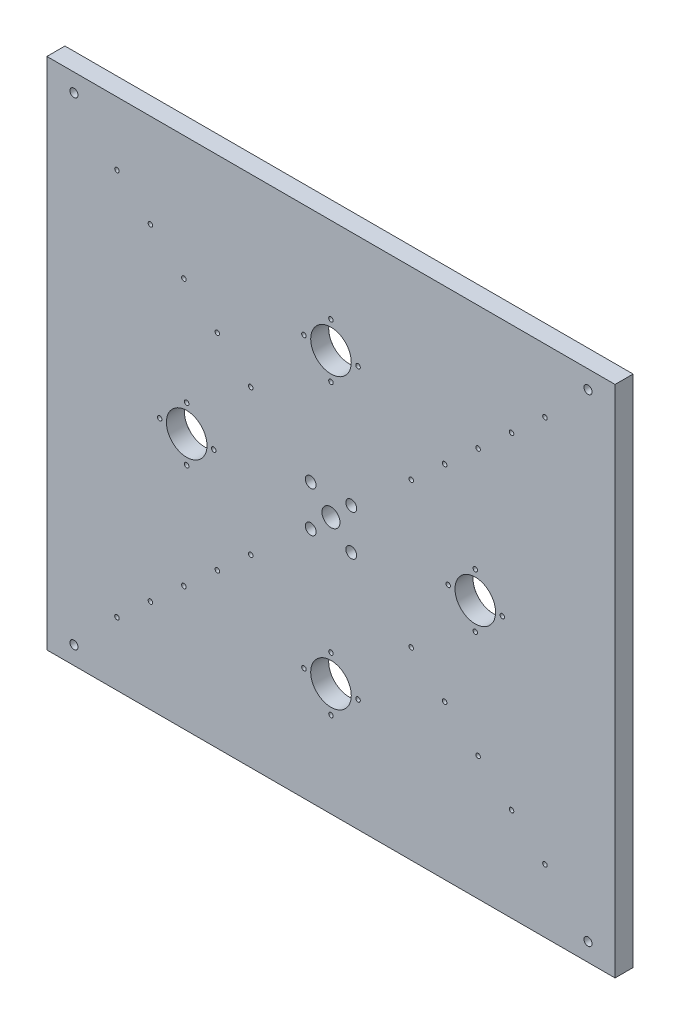
from build123d import *

# Parameters (mm, degrees)
SKETCH_1_W                  = 630
SKETCH_1_H                  = 570
EXTRUDE_1_DEPTH             = 20
MM_2_D                      = 20
MM_2_DEPTH                  = 20
MM_2_CSINK_D                = 20.05
MM_2_CSINK_ANGLE            = 90
MM_2_TIP                    = 6.00860619
HOLE_WIZARD_1_AT_2_COUNT    = 2
HOLE_WIZARD_1_AT_2_PITCH    = 570
HOLE_WIZARD_1_AT_3_COUNT    = 2
HOLE_WIZARD_1_AT_3_PITCH    = 778.331548892
HOLE_WIZARD_1_AT_4_COUNT    = 2
HOLE_WIZARD_1_AT_4_PITCH    = 530
HOLE_WIZARD_M6_1_AT_2_COUNT = 2
HOLE_WIZARD_M6_1_AT_2_PITCH = 50
HOLE_WIZARD_M6_1_AT_3_COUNT = 2
HOLE_WIZARD_M6_1_AT_3_PITCH = 100
HOLE_WIZARD_M6_1_AT_4_COUNT = 2
HOLE_WIZARD_M6_1_AT_4_PITCH = 150
HOLE_WIZARD_M6_1_AT_5_COUNT = 2
HOLE_WIZARD_M6_1_AT_5_PITCH = 200
MM_4_D                      = 12
MM_4_DEPTH                  = 22
MM_4_CSINK_D                = 12.05
MM_4_CSINK_ANGLE            = 90
MM_4_TIP                    = 3.605163714
MM_1_D                      = 45
MM_1_DEPTH                  = 24.5
MM_1_CSINK_D                = 45.1
MM_1_CSINK_ANGLE            = 90
MM_1_TIP                    = 13.519363928
HOLE_WIZARD_M6_2_AT_2_COUNT = 2
HOLE_WIZARD_M6_2_AT_2_PITCH = 42.426406871
HOLE_WIZARD_M6_2_AT_3_COUNT = 2
HOLE_WIZARD_M6_2_AT_3_PITCH = 60
HOLE_WIZARD_M6_2_AT_4_COUNT = 2
HOLE_WIZARD_M6_2_AT_4_PITCH = 42.426406871
HOLE_WIZARD_M6_3_AT_2_COUNT = 2
HOLE_WIZARD_M6_3_AT_2_PITCH = 42.426406871
HOLE_WIZARD_M6_3_AT_3_COUNT = 2
HOLE_WIZARD_M6_3_AT_3_PITCH = 60
HOLE_WIZARD_M6_3_AT_4_COUNT = 2
HOLE_WIZARD_M6_3_AT_4_PITCH = 42.426406871


with BuildPart() as part:
    # 草图1 → 凸台-拉伸1 (new body)
    with BuildSketch(Plane.XY):
        Rectangle(SKETCH_1_W, SKETCH_1_H)
    extrude(amount=EXTRUDE_1_DEPTH)

    # 大小mm 暗销槽口2
    with Locations(Plane(origin=(0, 0, 0), x_dir=(-1, 0, 0), z_dir=(0, 0, -1))):
        with Locations((0, 0)):
            CounterSinkHole(MM_2_D / 2, MM_2_CSINK_D / 2, depth=MM_2_DEPTH, counter_sink_angle=MM_2_CSINK_ANGLE)
            with Locations((0, 0, -(MM_2_DEPTH + MM_2_TIP / 2))):  # 118° drill point
                Cone(0, MM_2_D / 2, MM_2_TIP, mode=Mode.SUBTRACT)

    # 草图5 → 打孔尺寸(%根据)内六角圆柱头螺钉的类型1 (revolve, cut)
    with BuildSketch(Plane(origin=(285, 265, 0), x_dir=(0, 1, 0), z_dir=(1, 0, 0))):
        Polygon((0, 0), (0, 22.703872786), (4.5, 20), (4.5, 9), (7.5, 9), (7.5, 0.025), (7.525, 0), align=None)
    hole_wizard_1 = revolve(axis=Axis((285, 265, -6.35), (0, 0, 1)), mode=Mode.SUBTRACT)

    # 打孔尺寸(%根据)内六角圆柱头螺钉的类型1 at 2: 打孔尺寸(%根据)内六角圆柱头螺钉的类型1 ×2
    with Locations(*[(-i * HOLE_WIZARD_1_AT_2_PITCH, 0, 0) for i in range(1, HOLE_WIZARD_1_AT_2_COUNT)]):
        add(hole_wizard_1, mode=Mode.SUBTRACT)

    # 打孔尺寸(%根据)内六角圆柱头螺钉的类型1 at 3: 打孔尺寸(%根据)内六角圆柱头螺钉的类型1 ×2
    with Locations(*[Vector(-0.732335726, -0.680943745, 0) * (i * HOLE_WIZARD_1_AT_3_PITCH) for i in range(1, HOLE_WIZARD_1_AT_3_COUNT)]):
        add(hole_wizard_1, mode=Mode.SUBTRACT)

    # 打孔尺寸(%根据)内六角圆柱头螺钉的类型1 at 4: 打孔尺寸(%根据)内六角圆柱头螺钉的类型1 ×2
    with Locations(*[(0, -i * HOLE_WIZARD_1_AT_4_PITCH, 0) for i in range(1, HOLE_WIZARD_1_AT_4_COUNT)]):
        add(hole_wizard_1, mode=Mode.SUBTRACT)

    # 草图6 → M6 螺纹孔1 (revolve, cut)
    with BuildSketch(Plane(origin=(237.29144932, -214.69226367, 0), x_dir=(0, 1, 0), z_dir=(1, 0, 0))):
        Polygon((0, 0), (0, 31.502151548), (2.5, 30), (2.5, 0.525), (3.025, 0), align=None)
    hole_wizard_m6_1 = revolve(axis=Axis((237.29144932, -214.69226367, -6.35), (0, 0, 1)), mode=Mode.SUBTRACT)

    # M6 螺纹孔1 at 2: M6 螺纹孔1 ×2
    with Locations(*[Vector(-0.741535779, 0.670913324, 0) * (i * HOLE_WIZARD_M6_1_AT_2_PITCH) for i in range(1, HOLE_WIZARD_M6_1_AT_2_COUNT)]):
        add(hole_wizard_m6_1, mode=Mode.SUBTRACT)

    # M6 螺纹孔1 at 3: M6 螺纹孔1 ×2
    with Locations(*[Vector(-0.741535779, 0.670913324, 0) * (i * HOLE_WIZARD_M6_1_AT_3_PITCH) for i in range(1, HOLE_WIZARD_M6_1_AT_3_COUNT)]):
        add(hole_wizard_m6_1, mode=Mode.SUBTRACT)

    # M6 螺纹孔1 at 4: M6 螺纹孔1 ×2
    with Locations(*[Vector(-0.741535779, 0.670913324, 0) * (i * HOLE_WIZARD_M6_1_AT_4_PITCH) for i in range(1, HOLE_WIZARD_M6_1_AT_4_COUNT)]):
        add(hole_wizard_m6_1, mode=Mode.SUBTRACT)

    # M6 螺纹孔1 at 5: M6 螺纹孔1 ×2
    with Locations(*[Vector(-0.741535779, 0.670913324, 0) * (i * HOLE_WIZARD_M6_1_AT_5_PITCH) for i in range(1, HOLE_WIZARD_M6_1_AT_5_COUNT)]):
        add(hole_wizard_m6_1, mode=Mode.SUBTRACT)

    # 镜向1: M6 螺纹孔1 across plane
    add(hole_wizard_m6_1.mirror(Plane(origin=(0, 0, 0), x_dir=(0, 0, 1), z_dir=(1, 0, 0))), mode=Mode.SUBTRACT)

    # 镜向1 copy 1 sketch → 镜向1 copy 1 (revolve, cut)
    with BuildSketch(Plane(origin=(-200.214660363, -181.146597472, 0), x_dir=(0, 1, 0), z_dir=(-1, 0, 0))):
        Polygon((0, 0), (0, -31.502151548), (2.5, -30), (2.5, -0.525), (3.025, 0), align=None)
    revolve(axis=Axis((-200.214660363, -181.146597472, -6.35), (0, 0, -1)), mode=Mode.SUBTRACT)

    # 镜向1 copy 2 sketch → 镜向1 copy 2 (revolve, cut)
    with BuildSketch(Plane(origin=(-163.137871407, -147.600931273, 0), x_dir=(0, 1, 0), z_dir=(-1, 0, 0))):
        Polygon((0, 0), (0, -31.502151548), (2.5, -30), (2.5, -0.525), (3.025, 0), align=None)
    revolve(axis=Axis((-163.137871407, -147.600931273, -6.35), (0, 0, -1)), mode=Mode.SUBTRACT)

    # 镜向1 copy 3 sketch → 镜向1 copy 3 (revolve, cut)
    with BuildSketch(Plane(origin=(-126.061082451, -114.055265075, 0), x_dir=(0, 1, 0), z_dir=(-1, 0, 0))):
        Polygon((0, 0), (0, -31.502151548), (2.5, -30), (2.5, -0.525), (3.025, 0), align=None)
    revolve(axis=Axis((-126.061082451, -114.055265075, -6.35), (0, 0, -1)), mode=Mode.SUBTRACT)

    # 镜向1 copy 4 sketch → 镜向1 copy 4 (revolve, cut)
    with BuildSketch(Plane(origin=(-88.984293495, -80.509598876, 0), x_dir=(0, 1, 0), z_dir=(-1, 0, 0))):
        Polygon((0, 0), (0, -31.502151548), (2.5, -30), (2.5, -0.525), (3.025, 0), align=None)
    revolve(axis=Axis((-88.984293495, -80.509598876, -6.35), (0, 0, -1)), mode=Mode.SUBTRACT)

    # 镜向2: M6 螺纹孔1 across plane
    add(hole_wizard_m6_1.mirror(Plane.ZX), mode=Mode.SUBTRACT)

    # 镜向2 copy 1 sketch → 镜向2 copy 1 (revolve, cut)
    with BuildSketch(Plane(origin=(200.214660363, 181.146597472, 0), x_dir=(0, -1, 0), z_dir=(1, 0, 0))):
        Polygon((0, 0), (0, -31.502151548), (2.5, -30), (2.5, -0.525), (3.025, 0), align=None)
    revolve(axis=Axis((200.214660363, 181.146597472, -6.35), (0, 0, -1)), mode=Mode.SUBTRACT)

    # 镜向2 copy 2 sketch → 镜向2 copy 2 (revolve, cut)
    with BuildSketch(Plane(origin=(163.137871407, 147.600931273, 0), x_dir=(0, -1, 0), z_dir=(1, 0, 0))):
        Polygon((0, 0), (0, -31.502151548), (2.5, -30), (2.5, -0.525), (3.025, 0), align=None)
    revolve(axis=Axis((163.137871407, 147.600931273, -6.35), (0, 0, -1)), mode=Mode.SUBTRACT)

    # 镜向2 copy 3 sketch → 镜向2 copy 3 (revolve, cut)
    with BuildSketch(Plane(origin=(126.061082451, 114.055265075, 0), x_dir=(0, -1, 0), z_dir=(1, 0, 0))):
        Polygon((0, 0), (0, -31.502151548), (2.5, -30), (2.5, -0.525), (3.025, 0), align=None)
    revolve(axis=Axis((126.061082451, 114.055265075, -6.35), (0, 0, -1)), mode=Mode.SUBTRACT)

    # 镜向2 copy 4 sketch → 镜向2 copy 4 (revolve, cut)
    with BuildSketch(Plane(origin=(88.984293495, 80.509598876, 0), x_dir=(0, -1, 0), z_dir=(1, 0, 0))):
        Polygon((0, 0), (0, -31.502151548), (2.5, -30), (2.5, -0.525), (3.025, 0), align=None)
    revolve(axis=Axis((88.984293495, 80.509598876, -6.35), (0, 0, -1)), mode=Mode.SUBTRACT)

    # 镜向2 copy 5 sketch → 镜向2 copy 5 (revolve, cut)
    with BuildSketch(Plane(origin=(-237.29144932, 214.69226367, 0), x_dir=(0, -1, 0), z_dir=(-1, 0, 0))):
        Polygon((0, 0), (0, 31.502151548), (2.5, 30), (2.5, 0.525), (3.025, 0), align=None)
    revolve(axis=Axis((-237.29144932, 214.69226367, -6.35), (0, 0, 1)), mode=Mode.SUBTRACT)

    # 镜向2 copy 6 sketch → 镜向2 copy 6 (revolve, cut)
    with BuildSketch(Plane(origin=(-200.214660363, 181.146597472, 0), x_dir=(0, -1, 0), z_dir=(-1, 0, 0))):
        Polygon((0, 0), (0, 31.502151548), (2.5, 30), (2.5, 0.525), (3.025, 0), align=None)
    revolve(axis=Axis((-200.214660363, 181.146597472, -6.35), (0, 0, 1)), mode=Mode.SUBTRACT)

    # 镜向2 copy 7 sketch → 镜向2 copy 7 (revolve, cut)
    with BuildSketch(Plane(origin=(-163.137871407, 147.600931273, 0), x_dir=(0, -1, 0), z_dir=(-1, 0, 0))):
        Polygon((0, 0), (0, 31.502151548), (2.5, 30), (2.5, 0.525), (3.025, 0), align=None)
    revolve(axis=Axis((-163.137871407, 147.600931273, -6.35), (0, 0, 1)), mode=Mode.SUBTRACT)

    # 镜向2 copy 8 sketch → 镜向2 copy 8 (revolve, cut)
    with BuildSketch(Plane(origin=(-126.061082451, 114.055265075, 0), x_dir=(0, -1, 0), z_dir=(-1, 0, 0))):
        Polygon((0, 0), (0, 31.502151548), (2.5, 30), (2.5, 0.525), (3.025, 0), align=None)
    revolve(axis=Axis((-126.061082451, 114.055265075, -6.35), (0, 0, 1)), mode=Mode.SUBTRACT)

    # 镜向2 copy 9 sketch → 镜向2 copy 9 (revolve, cut)
    with BuildSketch(Plane(origin=(-88.984293495, 80.509598876, 0), x_dir=(0, -1, 0), z_dir=(-1, 0, 0))):
        Polygon((0, 0), (0, 31.502151548), (2.5, 30), (2.5, 0.525), (3.025, 0), align=None)
    revolve(axis=Axis((-88.984293495, 80.509598876, -6.35), (0, 0, 1)), mode=Mode.SUBTRACT)

    # 大小mm 暗销槽口4
    with Locations(Plane(origin=(0, 0, 0), x_dir=(-1, 0, 0), z_dir=(0, 0, -1))):
        with Locations((22.5, 22.5), (22.5, -22.5), (-22.5, -22.5), (-22.5, 22.5)):
            CounterSinkHole(MM_4_D / 2, MM_4_CSINK_D / 2, depth=MM_4_DEPTH, counter_sink_angle=MM_4_CSINK_ANGLE)
            with Locations((0, 0, -(MM_4_DEPTH + MM_4_TIP / 2))):  # 118° drill point
                Cone(0, MM_4_D / 2, MM_4_TIP, mode=Mode.SUBTRACT)

    # 大小mm 暗销孔1
    with Locations(Plane(origin=(160, 0, 0), x_dir=(-1, 0, 0), z_dir=(0, 0, -1))):
        with Locations((0, 0), (160, 160), (320, 0), (160, -160)):
            CounterSinkHole(MM_1_D / 2, MM_1_CSINK_D / 2, depth=MM_1_DEPTH, counter_sink_angle=MM_1_CSINK_ANGLE)
            with Locations((0, 0, -(MM_1_DEPTH + MM_1_TIP / 2))):  # 118° drill point
                Cone(0, MM_1_D / 2, MM_1_TIP, mode=Mode.SUBTRACT)

    # 草图10 → M6 螺纹孔2 (revolve, cut)
    with BuildSketch(Plane(origin=(-160, 30, 0), x_dir=(0, 1, 0), z_dir=(1, 0, 0))):
        Polygon((0, 0), (0, 21.502151548), (2.5, 20), (2.5, 0.525), (3.025, 0), align=None)
    hole_wizard_m6_2 = revolve(axis=Axis((-160, 30, -6.35), (0, 0, 1)), mode=Mode.SUBTRACT)

    # M6 螺纹孔2 at 2: M6 螺纹孔2 ×2
    with Locations(*[Vector(-0.707106781, -0.707106781, 0) * (i * HOLE_WIZARD_M6_2_AT_2_PITCH) for i in range(1, HOLE_WIZARD_M6_2_AT_2_COUNT)]):
        add(hole_wizard_m6_2, mode=Mode.SUBTRACT)

    # M6 螺纹孔2 at 3: M6 螺纹孔2 ×2
    with Locations(*[(0, -i * HOLE_WIZARD_M6_2_AT_3_PITCH, 0) for i in range(1, HOLE_WIZARD_M6_2_AT_3_COUNT)]):
        add(hole_wizard_m6_2, mode=Mode.SUBTRACT)

    # M6 螺纹孔2 at 4: M6 螺纹孔2 ×2
    with Locations(*[Vector(0.707106781, -0.707106781, 0) * (i * HOLE_WIZARD_M6_2_AT_4_PITCH) for i in range(1, HOLE_WIZARD_M6_2_AT_4_COUNT)]):
        add(hole_wizard_m6_2, mode=Mode.SUBTRACT)

    # 镜向3: M6 螺纹孔2 across plane
    add(hole_wizard_m6_2.mirror(Plane(origin=(0, 0, 0), x_dir=(0, 0, 1), z_dir=(1, 0, 0))), mode=Mode.SUBTRACT)

    # 镜向3 copy 1 sketch → 镜向3 copy 1 (revolve, cut)
    with BuildSketch(Plane(origin=(190, 0, 0), x_dir=(0, 1, 0), z_dir=(-1, 0, 0))):
        Polygon((0, 0), (0, -21.502151548), (2.5, -20), (2.5, -0.525), (3.025, 0), align=None)
    revolve(axis=Axis((190, 0, -6.35), (0, 0, -1)), mode=Mode.SUBTRACT)

    # 镜向3 copy 2 sketch → 镜向3 copy 2 (revolve, cut)
    with BuildSketch(Plane(origin=(160, -30, 0), x_dir=(0, 1, 0), z_dir=(-1, 0, 0))):
        Polygon((0, 0), (0, -21.502151548), (2.5, -20), (2.5, -0.525), (3.025, 0), align=None)
    revolve(axis=Axis((160, -30, -6.35), (0, 0, -1)), mode=Mode.SUBTRACT)

    # 镜向3 copy 3 sketch → 镜向3 copy 3 (revolve, cut)
    with BuildSketch(Plane(origin=(130, 0, 0), x_dir=(0, 1, 0), z_dir=(-1, 0, 0))):
        Polygon((0, 0), (0, -21.502151548), (2.5, -20), (2.5, -0.525), (3.025, 0), align=None)
    revolve(axis=Axis((130, 0, -6.35), (0, 0, -1)), mode=Mode.SUBTRACT)

    # 草图11 → M6 螺纹孔3 (revolve, cut)
    with BuildSketch(Plane(origin=(0, -130, 0), x_dir=(0, 1, 0), z_dir=(1, 0, 0))):
        Polygon((0, 0), (0, 21.502151548), (2.5, 20), (2.5, 0.525), (3.025, 0), align=None)
    hole_wizard_m6_3 = revolve(axis=Axis((0, -130, -6.35), (0, 0, 1)), mode=Mode.SUBTRACT)

    # M6 螺纹孔3 at 2: M6 螺纹孔3 ×2
    with Locations(*[Vector(-0.707106781, -0.707106781, 0) * (i * HOLE_WIZARD_M6_3_AT_2_PITCH) for i in range(1, HOLE_WIZARD_M6_3_AT_2_COUNT)]):
        add(hole_wizard_m6_3, mode=Mode.SUBTRACT)

    # M6 螺纹孔3 at 3: M6 螺纹孔3 ×2
    with Locations(*[(0, -i * HOLE_WIZARD_M6_3_AT_3_PITCH, 0) for i in range(1, HOLE_WIZARD_M6_3_AT_3_COUNT)]):
        add(hole_wizard_m6_3, mode=Mode.SUBTRACT)

    # M6 螺纹孔3 at 4: M6 螺纹孔3 ×2
    with Locations(*[Vector(0.707106781, -0.707106781, 0) * (i * HOLE_WIZARD_M6_3_AT_4_PITCH) for i in range(1, HOLE_WIZARD_M6_3_AT_4_COUNT)]):
        add(hole_wizard_m6_3, mode=Mode.SUBTRACT)

    # 镜向4: M6 螺纹孔3 across plane
    add(hole_wizard_m6_3.mirror(Plane.ZX), mode=Mode.SUBTRACT)

    # 镜向4 copy 1 sketch → 镜向4 copy 1 (revolve, cut)
    with BuildSketch(Plane(origin=(-30, 160, 0), x_dir=(0, -1, 0), z_dir=(1, 0, 0))):
        Polygon((0, 0), (0, -21.502151548), (2.5, -20), (2.5, -0.525), (3.025, 0), align=None)
    revolve(axis=Axis((-30, 160, -6.35), (0, 0, -1)), mode=Mode.SUBTRACT)

    # 镜向4 copy 2 sketch → 镜向4 copy 2 (revolve, cut)
    with BuildSketch(Plane(origin=(0, 190, 0), x_dir=(0, -1, 0), z_dir=(1, 0, 0))):
        Polygon((0, 0), (0, -21.502151548), (2.5, -20), (2.5, -0.525), (3.025, 0), align=None)
    revolve(axis=Axis((0, 190, -6.35), (0, 0, -1)), mode=Mode.SUBTRACT)

    # 镜向4 copy 3 sketch → 镜向4 copy 3 (revolve, cut)
    with BuildSketch(Plane(origin=(30, 160, 0), x_dir=(0, -1, 0), z_dir=(1, 0, 0))):
        Polygon((0, 0), (0, -21.502151548), (2.5, -20), (2.5, -0.525), (3.025, 0), align=None)
    revolve(axis=Axis((30, 160, -6.35), (0, 0, -1)), mode=Mode.SUBTRACT)


solid = part.part
